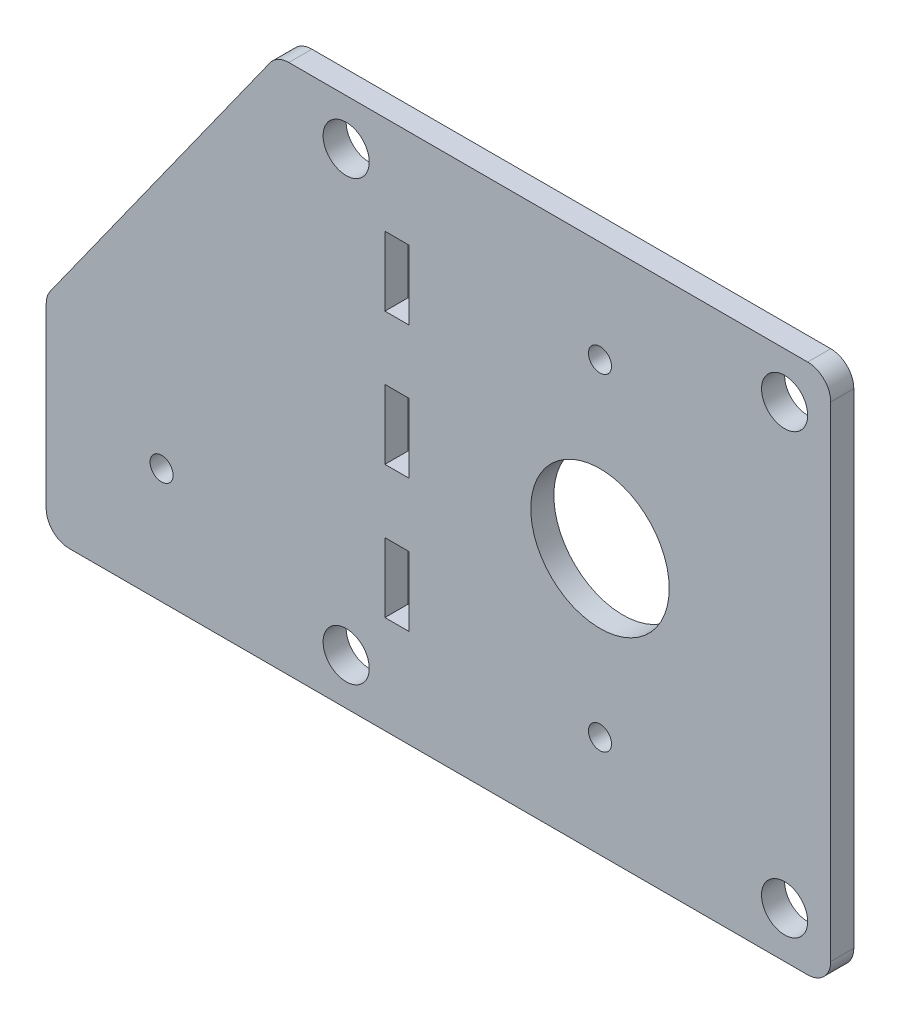
from build123d import *

# Parameters (mm, degrees)
SKETCH1_W           = 215.9
SKETCH1_H           = 146.05
SKETCH1_R           = 6.35
SKETCH1_R_2         = 19.05
SKETCH1_R_3         = 3.175
SKETCH1_W_2         = 6.604
SKETCH1_H_2         = 19.05
BOSS_EXTRUDE1_DEPTH = 3.175
SKETCH2_R           = 3.175
CUT_EXTRUDE1_DEPTH  = 7.35
FILLET1_R           = 6.35


with BuildPart() as part:
    # Sketch1 → Boss-Extrude1 (new body, symmetric)
    with BuildSketch(Plane.XY):
        with Locations((-44.45, 0)):
            Rectangle(SKETCH1_W, SKETCH1_H)
        with Locations((50.8, 60.325)):
            Circle(SKETCH1_R, mode=Mode.SUBTRACT)
        with Locations((50.8, -60.325)):
            Circle(SKETCH1_R, mode=Mode.SUBTRACT)
        Circle(SKETCH1_R_2, mode=Mode.SUBTRACT)
        with Locations((0, 45)):
            Circle(SKETCH1_R_3, mode=Mode.SUBTRACT)
        with Locations((0, -45)):
            Circle(SKETCH1_R_3, mode=Mode.SUBTRACT)
        with Locations((-69.85, 60.325)):
            Circle(SKETCH1_R, mode=Mode.SUBTRACT)
        with Locations((-69.85, -60.325)):
            Circle(SKETCH1_R, mode=Mode.SUBTRACT)
        with Locations((-55.88, 0)):
            Rectangle(SKETCH1_W_2, SKETCH1_H_2, mode=Mode.SUBTRACT)
        with Locations((-55.88, 36.5125)):
            Rectangle(SKETCH1_W_2, SKETCH1_H_2, mode=Mode.SUBTRACT)
        with Locations((-55.88, -36.5125)):
            Rectangle(SKETCH1_W_2, SKETCH1_H_2, mode=Mode.SUBTRACT)
    extrude(amount=BOSS_EXTRUDE1_DEPTH, both=True)

    # Sketch2 → Cut-Extrude1 (cut, through all)
    with BuildSketch(Plane.XY.offset(3.175)):
        with Locations((-120.65, -41.275)):
            Circle(SKETCH2_R)
        Polygon((-88.9, 73.025), (-152.4, -15.875), (-152.4, 73.025), align=None)
    extrude(amount=-CUT_EXTRUDE1_DEPTH, mode=Mode.SUBTRACT)

    # Fillet1
    fillet1_edges = [part.edges().sort_by_distance(p)[0] for p in [
        (63.5, 73.025, 0),
        (63.5, -73.025, 0),
        (-152.4, -73.025, 0),
        (-88.9, 73.025, 0),
        (-152.4, -15.875, 0),
    ]]
    fillet(fillet1_edges, radius=FILLET1_R)


solid = part.part
